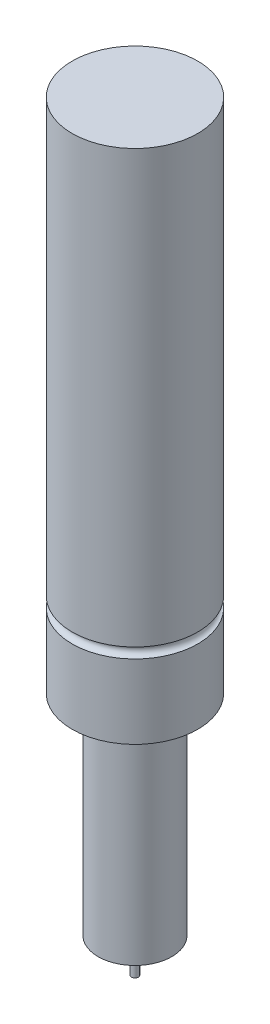
from build123d import *

# Parameters (mm, degrees)
ESQUISSE1_R        = 10.7
BOSS_EXTRU_1_DEPTH = 61
ESQUISSE2_R        = 18.25
BOSS_EXTRU_2_DEPTH = 150
ESQUISSE3_R        = 1
BOSS_EXTRU_3_DEPTH = 10


with BuildPart() as part:
    # Esquisse1 → Boss.-Extru.1 (new body)
    with BuildSketch(Plane(origin=(0, 0, 0), x_dir=(1, 0, 0), z_dir=(0, 1, 0))):
        Circle(ESQUISSE1_R)
    extrude(amount=-BOSS_EXTRU_1_DEPTH)

    # Esquisse2 → Boss.-Extru.2 (add)
    with BuildSketch(Plane(origin=(0, 0, 0), x_dir=(1, 0, 0), z_dir=(0, 1, 0))):
        Circle(ESQUISSE2_R)
    extrude(amount=BOSS_EXTRU_2_DEPTH)

    # Esquisse3 → Boss.-Extru.3 (add)
    with BuildSketch(Plane.XZ.offset(61)):
        Circle(ESQUISSE3_R)
    extrude(amount=BOSS_EXTRU_3_DEPTH)

    # Esquisse4 → Enlèvement de matière-Révolution1 (revolve, cut)
    with BuildSketch(Plane.XY):
        with BuildLine():
            Line((18.25, 21.5), (18.25, 24.5))
            ThreePointArc((18.25, 24.5), (16.75, 23), (18.25, 21.5))
        make_face()
    revolve(axis=Axis((0, 150, 0), (0, -1, 0)), mode=Mode.SUBTRACT)


solid = part.part
